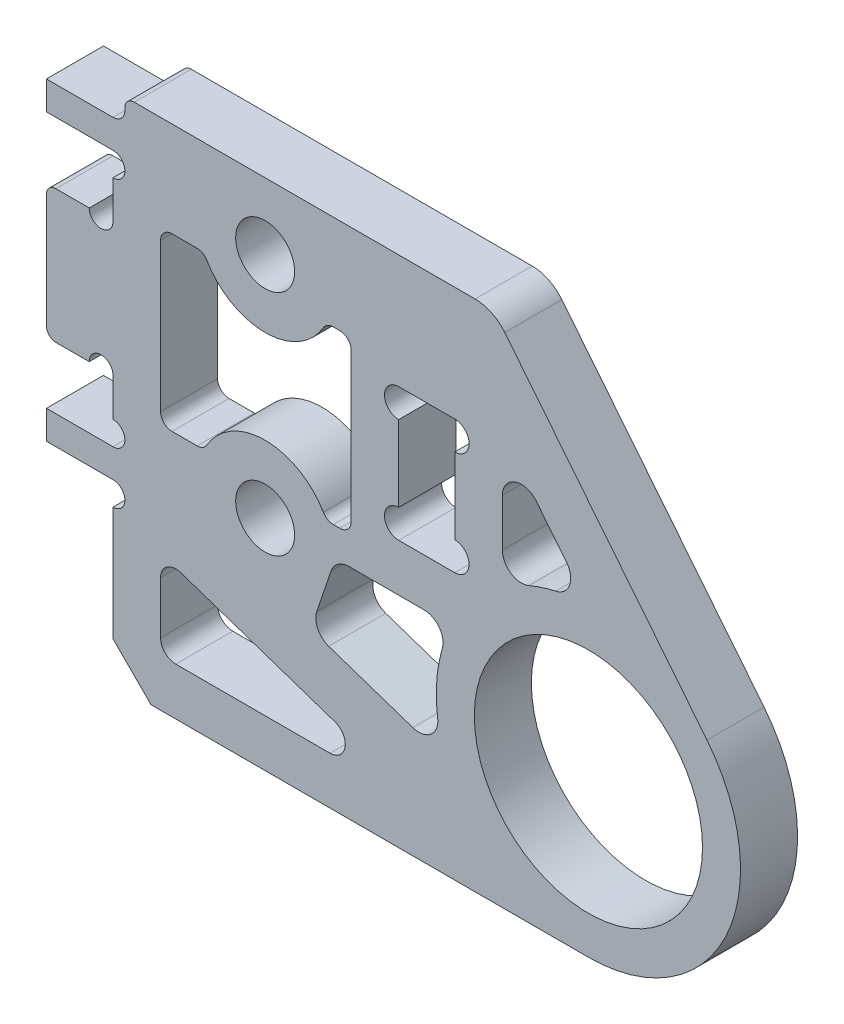
from build123d import *

# Parameters (mm, degrees)
SKETCH_1_R          = 6
EXTRUDE_1_DEPTH     = 1.5
SKETCH_2_W          = 3.5
SKETCH_2_H          = 7
SKETCH_2_H_2        = 1.5
EXTRUDE_2_DEPTH     = 3
SKETCH_3_R          = 0.625
CUT_EXTRUDE_1_DEPTH = 4
FILLET_1_R          = 0.5
SKETCH_4_R          = 1.55
SKETCH_4_W          = 2.95
SKETCH_4_H          = 7
CUT_EXTRUDE_2_DEPTH = 4
SKETCH_5_R          = 0.75
CUT_EXTRUDE_3_DEPTH = 4
CUT_EXTRUDE_4_DEPTH = 4
FILLET_2_R          = 0.6
CUT_EXTRUDE_5_DEPTH = 4
FILLET_3_R          = 1
EXTRUDE_3_DEPTH     = 3
FILLET_4_R          = 0.8
CHAMFER_1_SIZE      = 2
FILLET_6_R          = 2


with BuildPart() as part:
    # 草图1 → 凸台-拉伸1 (new body, symmetric)
    with BuildSketch(Plane.XY):
        with BuildLine():
            Line((-5, 19), (6.237156693, 5.009778077))
            ThreePointArc((6.237156693, 5.009778077), (6.557579277, -4.582374279), (-2.56, -7.579340341))
            Line((-2.56, -7.579340341), (-25, 0))
            Line((-25, 0), (-25, 19))
            Line((-25, 19), (-5, 19))
        make_face()
        Circle(SKETCH_1_R, mode=Mode.SUBTRACT)
    extrude(amount=EXTRUDE_1_DEPTH, both=True)

    # 草图2 → 凸台-拉伸2 (add)
    with BuildSketch(Plane.XY.offset(1.5)):
        with Locations((-26.75, 9.5)):
            Rectangle(SKETCH_2_W, SKETCH_2_H)
        with Locations((-26.75, 2)):
            Rectangle(SKETCH_2_W, SKETCH_2_H_2)
        with Locations((-26.75, 17)):
            Rectangle(SKETCH_2_W, SKETCH_2_H_2)
    extrude(amount=-EXTRUDE_2_DEPTH)

    # 草图3 → 切除-拉伸1 (cut, through all)
    with BuildSketch(Plane.XY.offset(1.5)):
        with Locations((-25, 15.625)):
            Circle(SKETCH_3_R)
        with Locations((-25, 18.375)):
            Circle(SKETCH_3_R)
        with Locations((-25, 3.375)):
            Circle(SKETCH_3_R)
        with Locations((-25, 0.625)):
            Circle(SKETCH_3_R)
        with Locations((-25.625, 6)):
            Circle(SKETCH_3_R)
        with Locations((-25.625, 13)):
            Circle(SKETCH_3_R)
    extrude(amount=-CUT_EXTRUDE_1_DEPTH, mode=Mode.SUBTRACT)

    # 圆角1
    fillet_1_edges = [part.edges().sort_by_distance(p)[0] for p in [
        (-28.5, 6, 0),
        (-28.5, 13, 0),
        (-25, 19, 0),
    ]]
    fillet(fillet_1_edges, radius=FILLET_1_R)

    # 草图4 → 切除-拉伸2 (cut, through all)
    with BuildSketch(Plane(origin=(0, 0, -1.5), x_dir=(-1, 0, 0), z_dir=(0, 0, -1))):
        with Locations((17, 15.5)):
            Circle(SKETCH_4_R)
        with Locations((17, 3.5)):
            Circle(SKETCH_4_R)
        with Locations((8.5, 9.5)):
            Rectangle(SKETCH_4_W, SKETCH_4_H)
    extrude(amount=-CUT_EXTRUDE_2_DEPTH, mode=Mode.SUBTRACT)

    # 草图5 → 切除-拉伸3 (cut, through all)
    with BuildSketch(Plane(origin=(0, 0, -1.5), x_dir=(-1, 0, 0), z_dir=(0, 0, -1))):
        with Locations((7.025, 12.25)):
            Circle(SKETCH_5_R)
        with Locations((9.975, 12.25)):
            Circle(SKETCH_5_R)
        with Locations((7.025, 6.75)):
            Circle(SKETCH_5_R)
        with Locations((9.975, 6.75)):
            Circle(SKETCH_5_R)
    extrude(amount=-CUT_EXTRUDE_3_DEPTH, mode=Mode.SUBTRACT)

    # 草图6 → 切除-拉伸4 (cut, through all)
    with BuildSketch(Plane(origin=(0, 0, -1.5), x_dir=(-1, 0, 0), z_dir=(0, 0, -1))):
        with BuildLine():
            Line((12.475, 14), (12.475, 5))
            Line((12.475, 5), (13.782469891, 5))
            ThreePointArc((13.782469891, 5), (17, 7.05), (20.217530109, 5))
            Line((20.217530109, 5), (22.5, 5))
            Line((22.5, 5), (22.5, 14))
            Line((22.5, 14), (20.217530109, 14))
            ThreePointArc((20.217530109, 14), (17, 11.95), (13.782469891, 14))
            Line((13.782469891, 14), (12.475, 14))
        make_face()
    extrude(amount=-CUT_EXTRUDE_4_DEPTH, mode=Mode.SUBTRACT)

    # 圆角2
    fillet_2_edges = [part.edges().sort_by_distance(p)[0] for p in [
        (-12.475, 14, 0),
        (-13.782469891, 14, 0),
        (-20.217530109, 14, 0),
        (-22.5, 14, 0),
        (-22.5, 5, 0),
        (-20.217530109, 5, 0),
        (-13.782469891, 5, 0),
        (-12.475, 5, 0),
    ]]
    fillet(fillet_2_edges, radius=FILLET_2_R)

    # 草图7 → 切除-拉伸5 (cut, through all)
    with BuildSketch(Plane(origin=(0, 0, -1.5), x_dir=(-1, 0, 0), z_dir=(0, 0, -1))):
        with BuildLine():
            Line((7.193747285, 3.5), (13.305747104, 3.5))
            Line((13.305747104, 3.5), (14.604346249, -0.344736281))
            Line((14.604346249, -0.344736281), (7.516620657, -2.738688353))
            ThreePointArc((7.516620657, -2.738688353), (7.989307814, 0.413473892), (7.193747285, 3.5))
        make_face()
        with BuildLine():
            Line((4.525, 13.617995246), (0.012533825, 7.999990181))
            ThreePointArc((0.012533825, 7.999990181), (2.374697418, 7.639424859), (4.525, 6.597300584))
            Line((4.525, 6.597300584), (4.525, 13.617995246))
        make_face()
    extrude(amount=-CUT_EXTRUDE_5_DEPTH, mode=Mode.SUBTRACT)

    # 圆角3
    fillet_3_edges = [part.edges().sort_by_distance(p)[0] for p in [
        (-7.516620657, -2.738688353, 0),
        (-7.193747285, 3.5, 0),
        (-13.305747104, 3.5, 0),
        (-14.604346249, -0.344736281, 0),
        (-4.525, 13.617995246, 0),
        (-4.525, 6.597300584, 0),
        (-0.012533825, 7.999990181, 0),
    ]]
    fillet(fillet_3_edges, radius=FILLET_3_R)

    # 草图8 → 凸台-拉伸3 (add)
    with BuildSketch(Plane.XY.offset(1.5)):
        with BuildLine():
            Line((-25, 0), (-25, -8))
            Line((-25, -8), (0, -8))
            ThreePointArc((0, -8), (-1.297165617, -7.894134618), (-2.56, -7.579340341))
            Line((-2.56, -7.579340341), (-8.716260987, -5.5))
            Line((-8.716260987, -5.5), (-22.5, -5.5))
            Line((-22.5, -5.5), (-22.5, -0.844400662))
            Line((-22.5, -0.844400662), (-25, 0))
        make_face()
    extrude(amount=-EXTRUDE_3_DEPTH)

    # 圆角4
    fillet_4_edges = [part.edges().sort_by_distance(p)[0] for p in [
        (-22.5, -0.844400662, 0),
        (-22.5, -5.5, 0),
        (-8.716260987, -5.5, 0),
    ]]
    fillet(fillet_4_edges, radius=FILLET_4_R)

    # 倒角1
    chamfer_1_edges = [part.edges().sort_by_distance(p)[0] for p in [
        (-25, -8, 0),
    ]]
    chamfer(chamfer_1_edges, length=CHAMFER_1_SIZE)

    # 圆角6
    fillet_6_edges = [part.edges().sort_by_distance(p)[0] for p in [
        (-5, 19, 0),
    ]]
    fillet(fillet_6_edges, radius=FILLET_6_R)


solid = part.part
